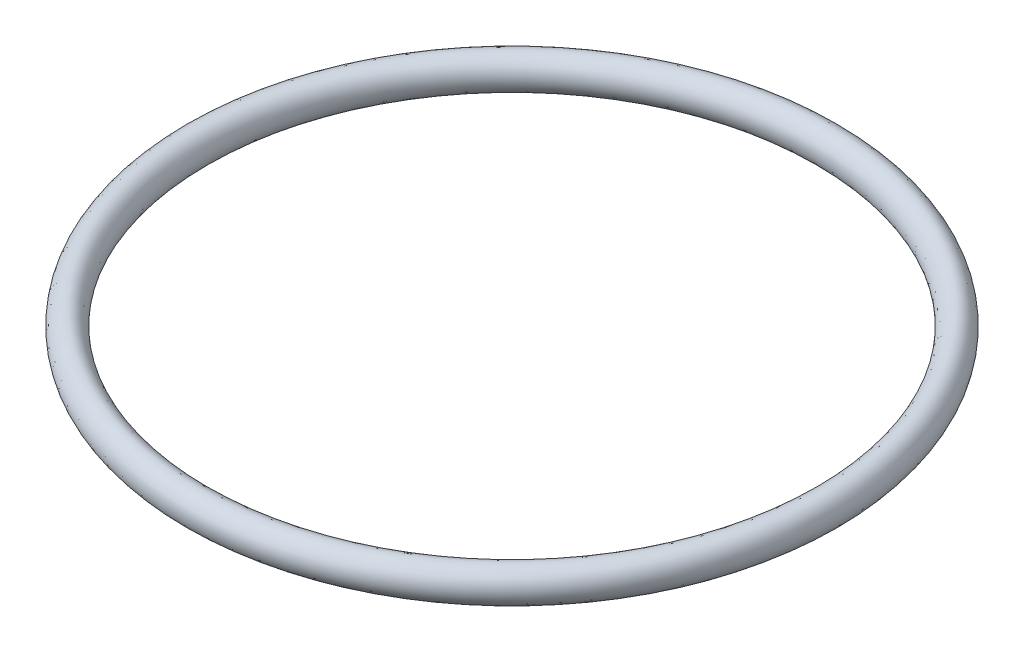
from build123d import *

# Parameters (mm, degrees)
SKETCH1_RX = 1.9
SKETCH1_RY = 1.7


with BuildPart() as part:
    # Sketch1 → Revolve1 (revolve)
    with BuildSketch(Plane.XY):
        with Locations(Location((-35.15, 0), (0, 0, 90))):
            Ellipse(SKETCH1_RX, SKETCH1_RY)
    revolve(axis=Axis((0, 0, 0), (0, 1, 0)))


solid = part.part
